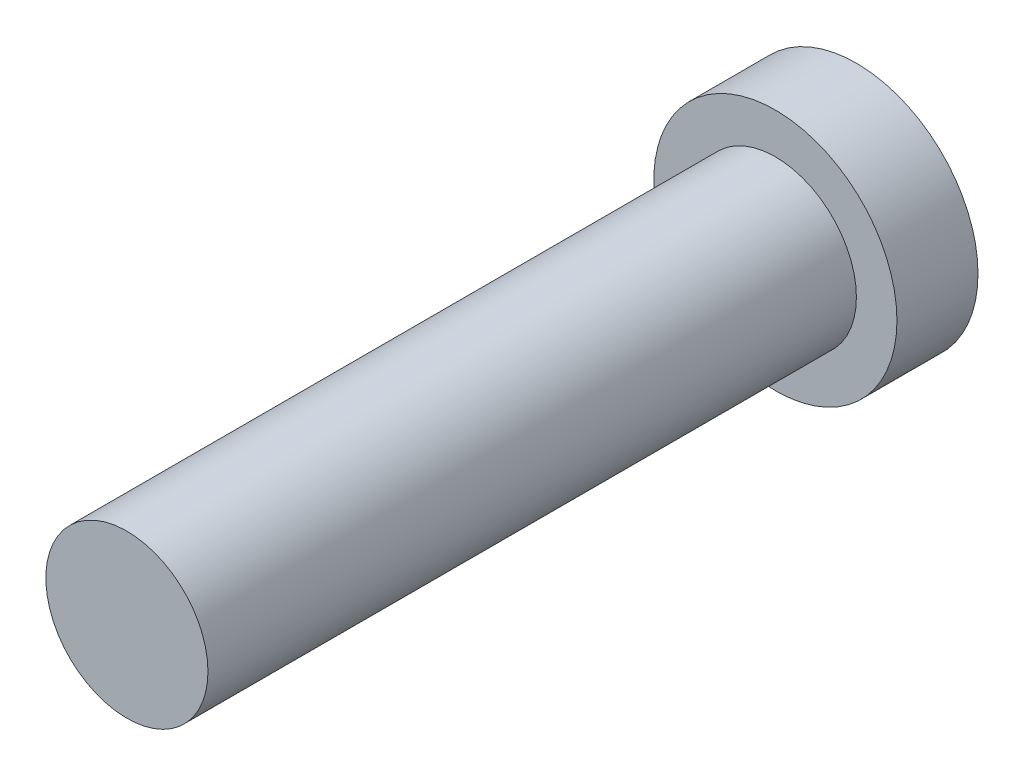
from build123d import *

# Parameters (mm, degrees)
SKETCH2_R           = 19.05
BOSS_EXTRUDE1_DEPTH = 6.35
SKETCH3_R           = 12.7
BOSS_EXTRUDE2_DEPTH = 101.6


with BuildPart() as part:
    # Sketch2 → Boss-Extrude1 (new body, symmetric)
    with BuildSketch(Plane.XY):
        Circle(SKETCH2_R)
    extrude(amount=BOSS_EXTRUDE1_DEPTH, both=True)

    # Sketch3 → Boss-Extrude2 (add)
    with BuildSketch(Plane.XY.offset(6.35)):
        Circle(SKETCH3_R)
    extrude(amount=BOSS_EXTRUDE2_DEPTH)


solid = part.part
